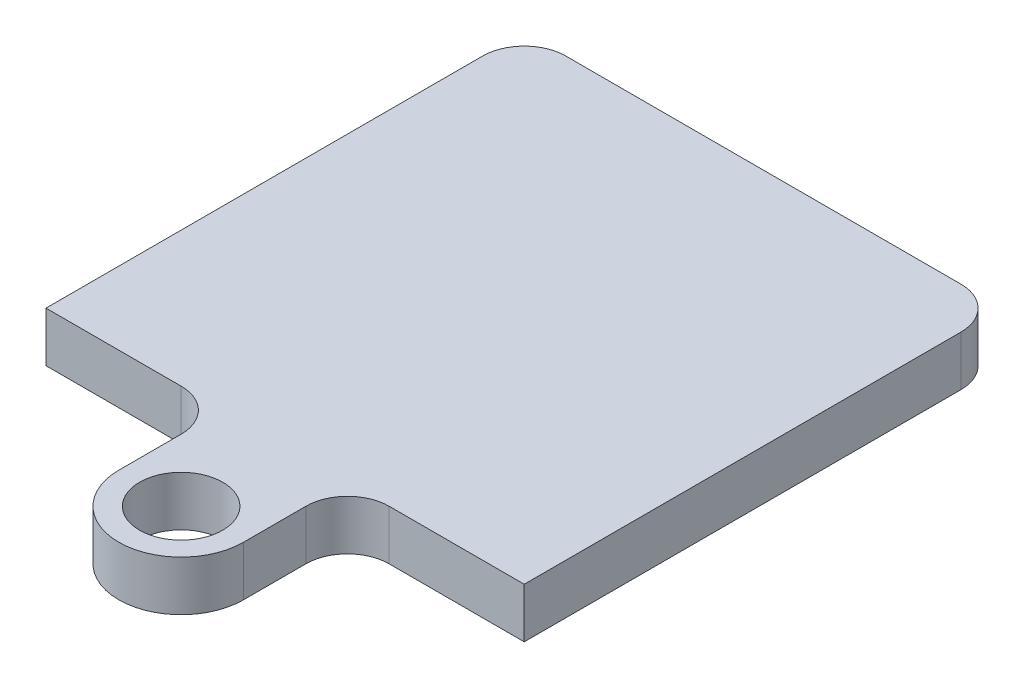
from build123d import *

# Parameters (mm, degrees)
SKETCH1_W           = 23
SKETCH1_H           = 23
BOSS_EXTRUDE1_DEPTH = 2.4
FILLET1_R           = 2
SKETCH2_R           = 2
BOSS_EXTRUDE2_DEPTH = 2.4
FILLET2_R           = 2


with BuildPart() as part:
    # Sketch1 → Boss-Extrude1 (new body)
    with BuildSketch(Plane(origin=(0, 0, 0), x_dir=(1, 0, 0), z_dir=(0, 1, 0))):
        Rectangle(SKETCH1_W, SKETCH1_H)
    extrude(amount=BOSS_EXTRUDE1_DEPTH)

    # Fillet1
    fillet1_edges = [part.edges().sort_by_distance(p)[0] for p in [
        (-11.5, 1.2, -11.5),
        (11.5, 1.2, -11.5),
    ]]
    fillet(fillet1_edges, radius=FILLET1_R)

    # Sketch2 → Boss-Extrude2 (add)
    with BuildSketch(Plane(origin=(0, 2.4, 0), x_dir=(1, 0, 0), z_dir=(0, 1, 0))):
        with BuildLine():
            Line((-3, -11.5), (-3, -16.5))
            ThreePointArc((-3, -16.5), (0, -19.5), (3, -16.5))
            Line((3, -16.5), (3, -11.5))
            Line((3, -11.5), (-3, -11.5))
        make_face()
        with Locations((0, -16.5)):
            Circle(SKETCH2_R, mode=Mode.SUBTRACT)
    extrude(amount=-BOSS_EXTRUDE2_DEPTH)

    # Fillet2
    fillet2_edges = [part.edges().sort_by_distance(p)[0] for p in [
        (3, 1.2, 11.5),
        (-3, 1.2, 11.5),
    ]]
    fillet(fillet2_edges, radius=FILLET2_R)


solid = part.part
